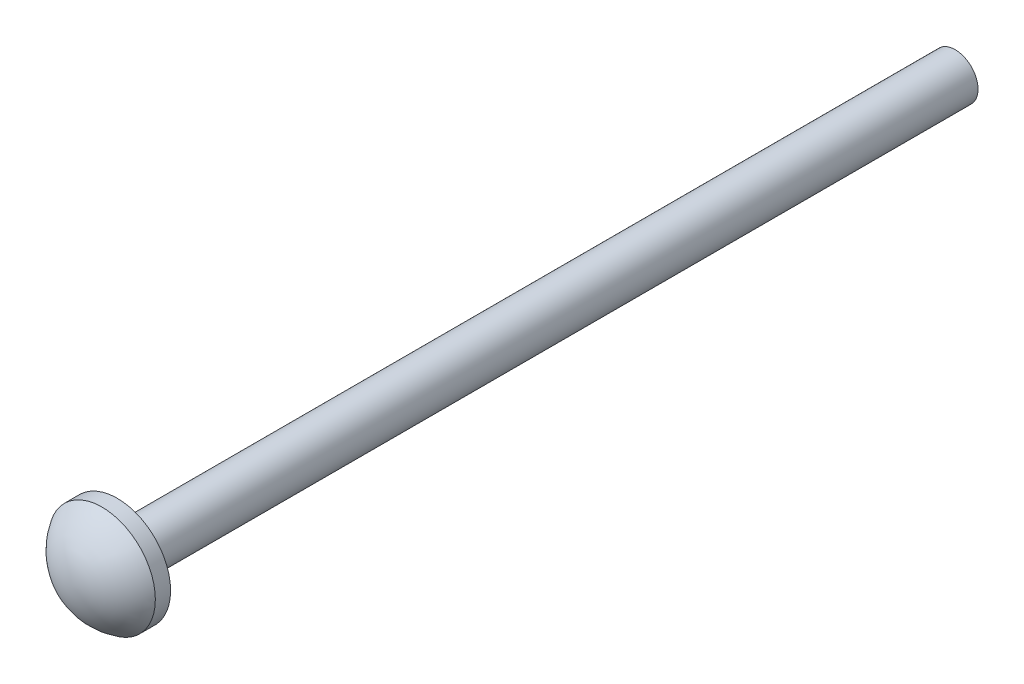
from build123d import *

# Parameters (mm, degrees)
SKETCH1_R           = 3.5
BOSS_EXTRUDE1_DEPTH = 1
DOME1_FACE_RADIUS   = 3.5
DOME1_HEIGHT        = 2
SKETCH3_R           = 1.5
BOSS_EXTRUDE2_DEPTH = 55


with BuildPart() as part:
    # Sketch1 → Boss-Extrude1 (new body)
    with BuildSketch(Plane.XY):
        Circle(SKETCH1_R)
    extrude(amount=BOSS_EXTRUDE1_DEPTH)

    # Dome1: a dome of height H over a round flat face of radius A is a cap of a sphere of radius (A * A + H * H) / (2 * H)
    dome1_r = (DOME1_FACE_RADIUS * DOME1_FACE_RADIUS + DOME1_HEIGHT * DOME1_HEIGHT) / (2 * DOME1_HEIGHT)
    dome1_base = Plane((0, 0, 1), z_dir=(0, 0, 1))
    with Locations(dome1_base.offset(DOME1_HEIGHT - dome1_r)):
        dome1_ball = Sphere(dome1_r, mode=Mode.PRIVATE)
    add(split(dome1_ball, bisect_by=dome1_base, keep=Keep.TOP, mode=Mode.PRIVATE))

    # Sketch3 → Boss-Extrude2 (add)
    with BuildSketch(Plane(origin=(0, 0, 0), x_dir=(-1, 0, 0), z_dir=(0, 0, -1))):
        Circle(SKETCH3_R)
    extrude(amount=BOSS_EXTRUDE2_DEPTH)


solid = part.part
